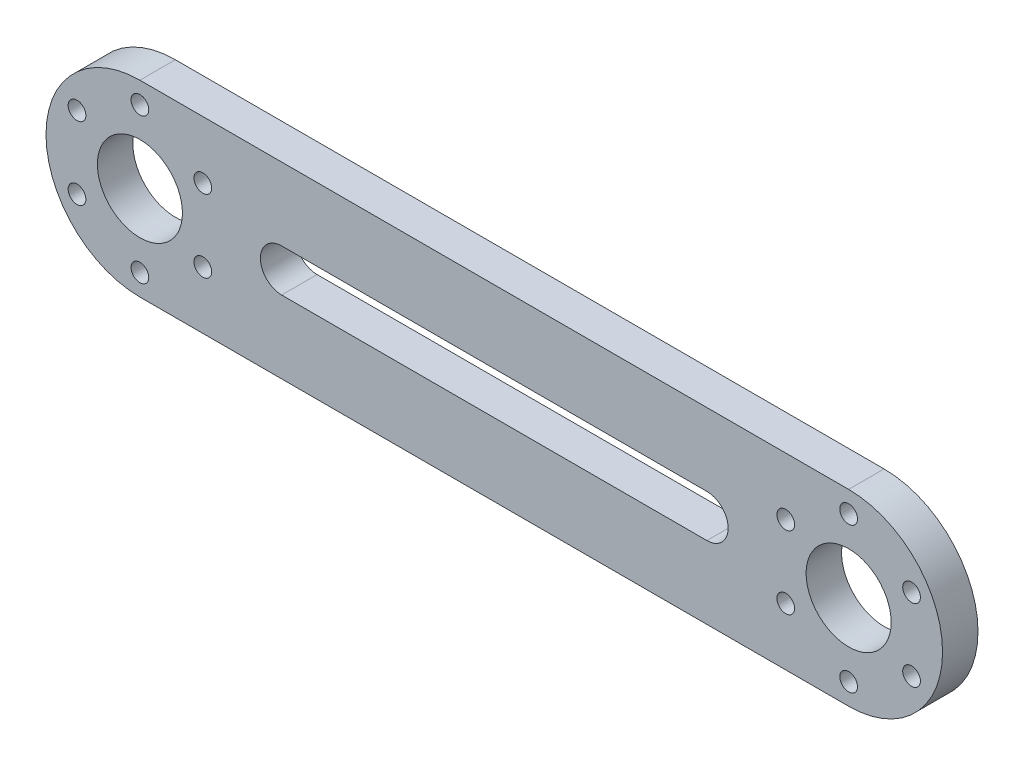
from build123d import *

# Parameters (mm, degrees)
SKETCH1_R           = 13.25
SKETCH1_R_2         = 6
BOSS_EXTRUDE1_DEPTH = 5
SKETCH2_R           = 1.25
CUT_EXTRUDE1_DEPTH  = 6


with BuildPart() as part:
    # Sketch1 → Boss-Extrude1 (new body)
    with BuildSketch(Plane.XY):
        Circle(SKETCH1_R)
        Circle(SKETCH1_R_2, mode=Mode.SUBTRACT)
        with BuildLine():
            Line((100, 13.25), (0, 13.25))
            ThreePointArc((0, 13.25), (9.369164851, 9.369164851), (13.25, 0))
            ThreePointArc((13.25, 0), (9.369164851, -9.369164851), (0, -13.25))
            Line((0, -13.25), (100, -13.25))
            ThreePointArc((100, -13.25), (86.75, 0), (100, 13.25))
        make_face()
        with BuildLine():
            Line((80, -3), (50, -3))
            Line((50, -3), (20, -3))
            ThreePointArc((20, -3), (17, 0), (20, 3))
            Line((20, 3), (50, 3))
            Line((50, 3), (80, 3))
            ThreePointArc((80, 3), (82.121320344, 2.121320344), (83, 0))
            ThreePointArc((83, 0), (82.121320344, -2.121320344), (80, -3))
        make_face(mode=Mode.SUBTRACT)
        with Locations((100, 0)):
            Circle(SKETCH1_R)
        with Locations((100, 0)):
            Circle(SKETCH1_R_2, mode=Mode.SUBTRACT)
    extrude(amount=BOSS_EXTRUDE1_DEPTH)

    # Sketch2 → Cut-Extrude1 (cut, through all)
    with BuildSketch(Plane.XY.offset(5)):
        with Locations((100, 10.25)):
            Circle(SKETCH2_R)
        with Locations((108.876760389, 5.125)):
            Circle(SKETCH2_R)
        with Locations((8.876760389, 5.125)):
            Circle(SKETCH2_R)
        with Locations((8.876760389, -5.125)):
            Circle(SKETCH2_R)
        with Locations((-8.876760389, 5.125)):
            Circle(SKETCH2_R)
        with Locations((-8.876760389, -5.125)):
            Circle(SKETCH2_R)
        with Locations((0, -10.25)):
            Circle(SKETCH2_R)
        with Locations((0, 10.25)):
            Circle(SKETCH2_R)
        with Locations((91.123239611, 5.125)):
            Circle(SKETCH2_R)
        with Locations((108.876760389, -5.125)):
            Circle(SKETCH2_R)
        with Locations((100, -10.25)):
            Circle(SKETCH2_R)
        with Locations((91.123239611, -5.125)):
            Circle(SKETCH2_R)
    extrude(amount=-CUT_EXTRUDE1_DEPTH, mode=Mode.SUBTRACT)


solid = part.part
